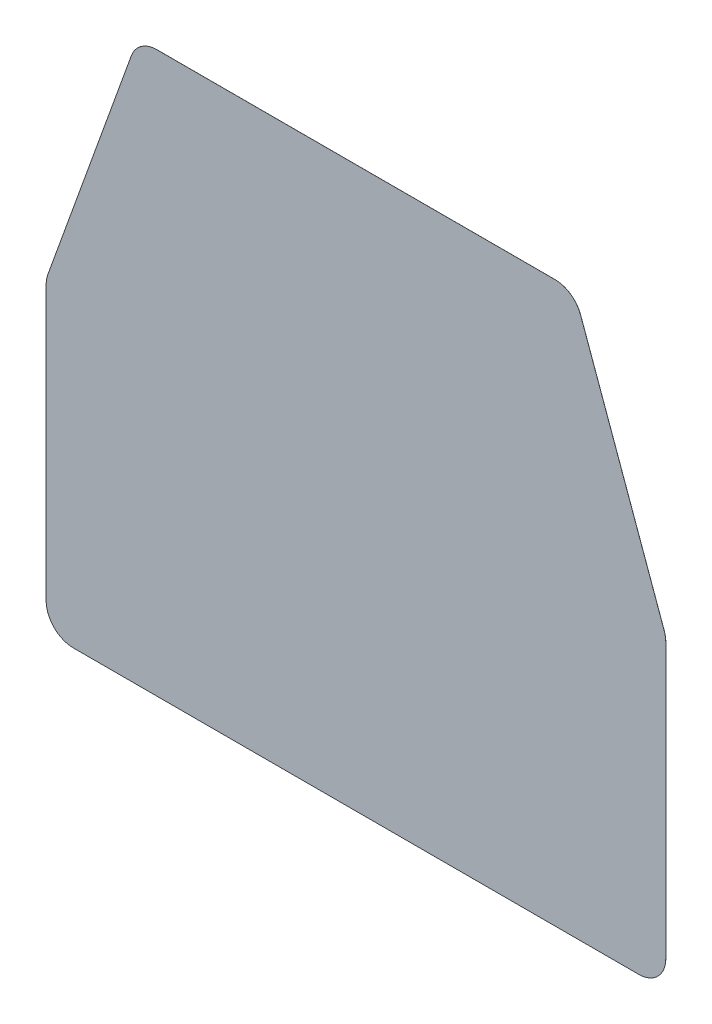
from build123d import *

# Parameters (mm, degrees)
BOSS_EXTRUDE1_DEPTH = 0.0254


with BuildPart() as part:
    # Sketch1 → Boss-Extrude1 (new body)
    with BuildSketch(Plane.XY):
        with BuildLine():
            Line((-132.08, 0), (132.08, 0))
            ThreePointArc((132.08, 0), (141.060256121, 3.719743879), (144.78, 12.7))
            Line((144.78, 12.7), (144.78, 140.779102188))
            ThreePointArc((144.78, 140.779102188), (144.58982039, 142.968712611), (144.024977353, 145.092745199))
            Line((144.024977353, 145.092745199), (104.972477353, 253.233643011))
            ThreePointArc((104.972477353, 253.233643011), (100.324990451, 259.314067208), (93.0275, 261.62))
            Line((93.0275, 261.62), (-93.0275, 261.62))
            ThreePointArc((-93.0275, 261.62), (-100.324990451, 259.314067208), (-104.972477353, 253.233643011))
            Line((-104.972477353, 253.233643011), (-144.024977353, 145.092745199))
            ThreePointArc((-144.024977353, 145.092745199), (-144.58982039, 142.968712611), (-144.78, 140.779102188))
            Line((-144.78, 140.779102188), (-144.78, 12.7))
            ThreePointArc((-144.78, 12.7), (-141.060256121, 3.719743879), (-132.08, 0))
        make_face()
    extrude(amount=BOSS_EXTRUDE1_DEPTH)


solid = part.part
